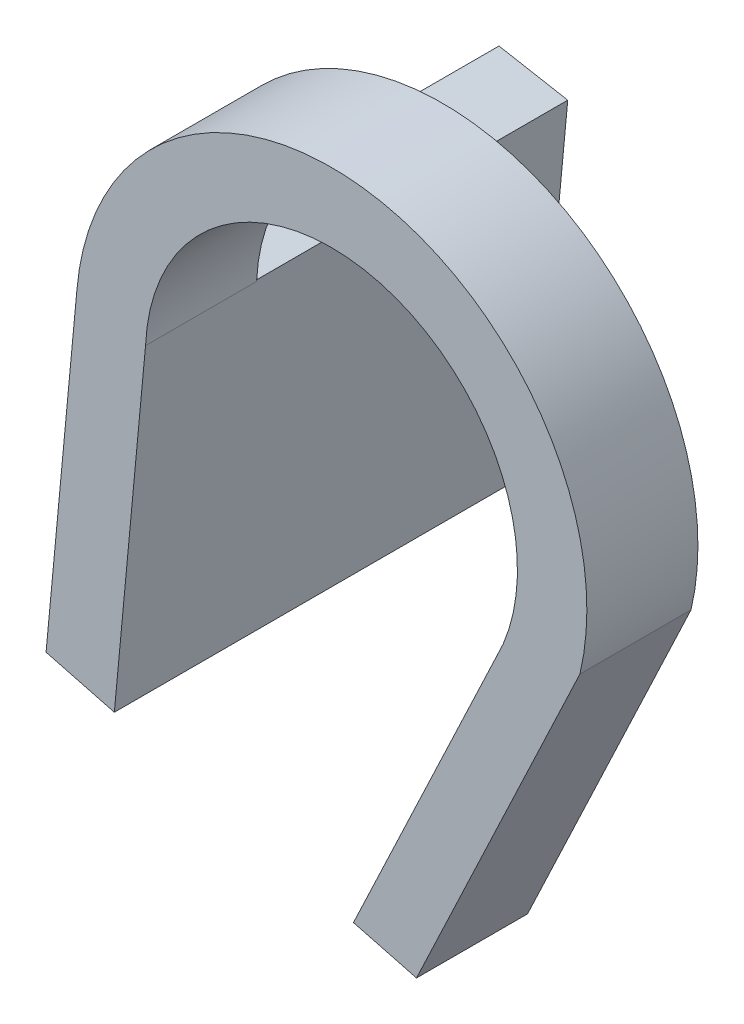
from build123d import *

# Parameters (mm, degrees)
BOSS_EXTRUDE3_DEPTH = 10
BOSS_EXTRUDE4_DEPTH = 28


with BuildPart() as part:
    # Sketch1 → Boss-Extrude3 (new body)
    with BuildSketch(Plane.XY):
        with BuildLine():
            ThreePointArc((-16.733879942, 0.734685024), (4.365374373, 16.171147349), (14.830379862, -7.786034495))
            Line((14.830379862, -7.786034495), (1.98558973, -34.897127547))
            Line((1.98558973, -34.897127547), (7.660402975, -36.381590217))
            Line((7.660402975, -36.381590217), (22.375667903, -5.322545058))
            ThreePointArc((22.375667903, -5.322545058), (3.672252171, 22.704945805), (-22.912677541, 2.002300652))
            Line((-22.912677541, 2.002300652), (-25.690659105, -27.657354808))
            Line((-25.690659105, -27.657354808), (-19.543738844, -29.265314976))
            Line((-19.543738844, -29.265314976), (-16.733879942, 0.734685024))
        make_face()
    extrude(amount=BOSS_EXTRUDE3_DEPTH)

    # Sketch2 → Boss-Extrude4 (add)
    with BuildSketch(Plane(origin=(0, 0, 0), x_dir=(-1, 0, 0), z_dir=(0, 0, -1))):
        Polygon((22.912677541, 2.002300652), (16.720636216, 0.876084213), (19.543738844, -29.265314976), (25.690659105, -27.657354808), align=None)
    extrude(amount=BOSS_EXTRUDE4_DEPTH)


solid = part.part
